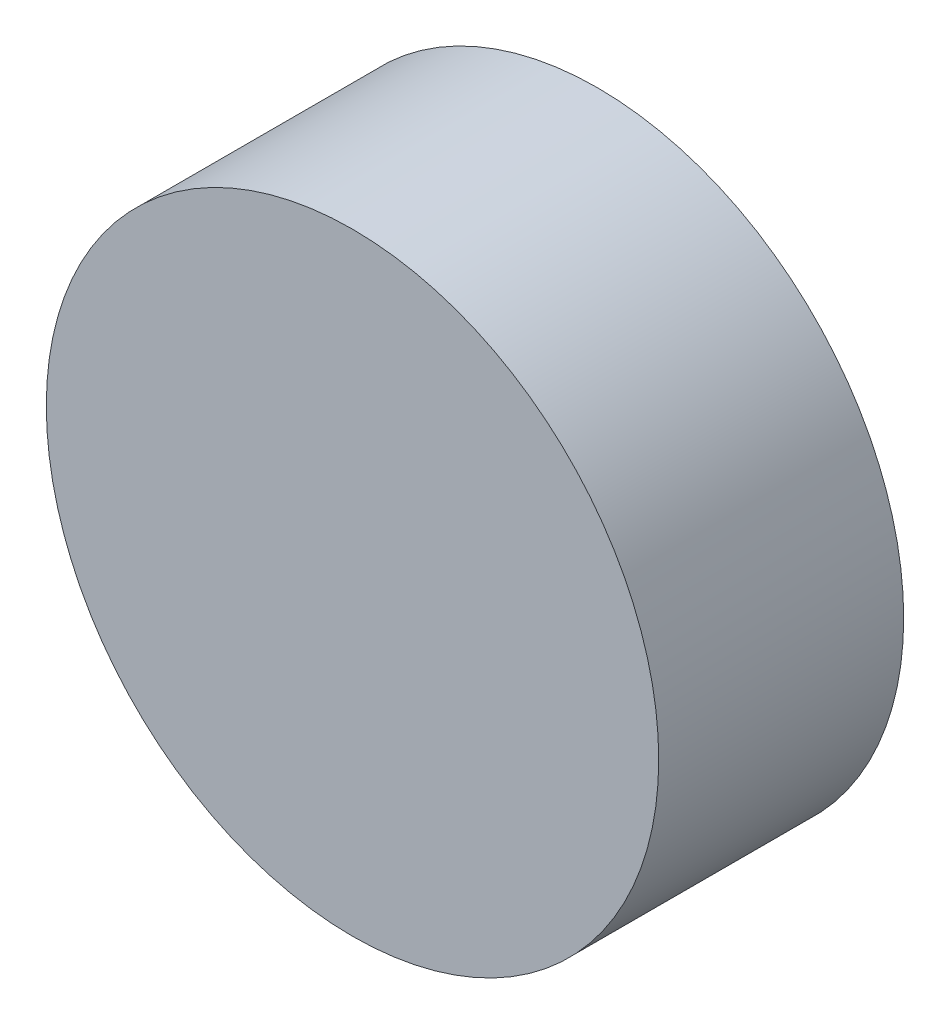
from build123d import *

# Parameters (mm, degrees)
SKETCH1_R           = 2.5
BOSS_EXTRUDE1_DEPTH = 1


with BuildPart() as part:
    # Sketch1 → Boss-Extrude1 (new body, symmetric)
    with BuildSketch(Plane.XY):
        Circle(SKETCH1_R)
    extrude(amount=BOSS_EXTRUDE1_DEPTH, both=True)


solid = part.part
